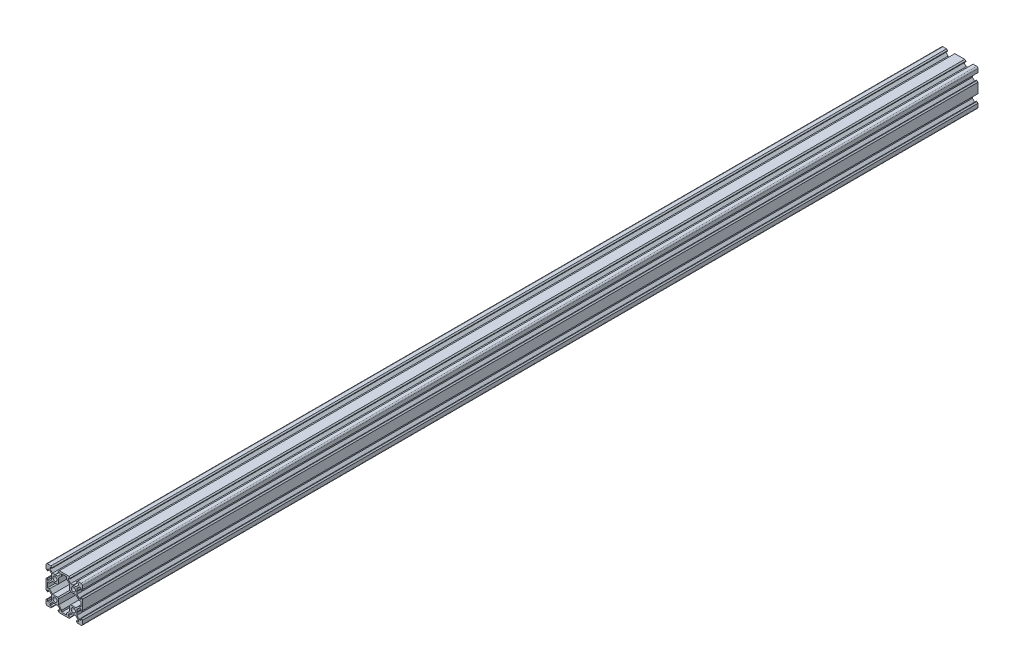
from build123d import *

# Parameters (mm, degrees)
SKETCH1_R           = 2.3
BOSS_EXTRUDE1_DEPTH = 984.25


with BuildPart() as part:
    # Sketch1 → Boss-Extrude1 (new body)
    with BuildSketch(Plane.XY):
        with BuildLine():
            Line((14.58, -20), (18.5, -20))
            ThreePointArc((18.5, -20), (19.560660172, -19.560660172), (20, -18.5))
            Line((20, -18.5), (20, -14.58))
            Line((20, -14.58), (18.815, -13.395))
            Line((18.815, -13.395), (18.2, -13.395))
            Line((18.2, -13.395), (18.2, -15.5))
            Line((18.2, -15.5), (16.560660172, -15.5))
            Line((16.560660172, -15.5), (13.9, -12.839339828))
            Line((13.9, -12.839339828), (13.9, -10.21))
            Line((13.9, -10.21), (13.69, -10))
            Line((13.69, -10), (13.9, -9.79))
            Line((13.9, -9.79), (13.9, -7.160660172))
            Line((13.9, -7.160660172), (16.560660172, -4.5))
            Line((16.560660172, -4.5), (18.2, -4.5))
            Line((18.2, -4.5), (18.2, -6.605))
            Line((18.2, -6.605), (18.815, -6.605))
            Line((18.815, -6.605), (20, -5.42))
            Line((20, -5.42), (20, 5.42))
            Line((20, 5.42), (18.815, 6.605))
            Line((18.815, 6.605), (18.2, 6.605))
            Line((18.2, 6.605), (18.2, 4.5))
            Line((18.2, 4.5), (16.560660172, 4.5))
            Line((16.560660172, 4.5), (13.9, 7.160660172))
            Line((13.9, 7.160660172), (13.9, 9.79))
            Line((13.9, 9.79), (13.69, 10))
            Line((13.69, 10), (13.9, 10.21))
            Line((13.9, 10.21), (13.9, 12.839339828))
            Line((13.9, 12.839339828), (16.560660172, 15.5))
            Line((16.560660172, 15.5), (18.2, 15.5))
            Line((18.2, 15.5), (18.2, 13.395))
            Line((18.2, 13.395), (18.815, 13.395))
            Line((18.815, 13.395), (20, 14.58))
            Line((20, 14.58), (20, 18.5))
            ThreePointArc((20, 18.5), (19.560660172, 19.560660172), (18.5, 20))
            Line((18.5, 20), (14.58, 20))
            Line((14.58, 20), (13.395, 18.815))
            Line((13.395, 18.815), (13.395, 18.2))
            Line((13.395, 18.2), (15.5, 18.2))
            Line((15.5, 18.2), (15.5, 16.560660172))
            Line((15.5, 16.560660172), (12.839339828, 13.9))
            Line((12.839339828, 13.9), (10.21, 13.9))
            Line((10.21, 13.9), (10, 13.69))
            Line((10, 13.69), (9.79, 13.9))
            Line((9.79, 13.9), (7.160660172, 13.9))
            Line((7.160660172, 13.9), (4.5, 16.560660172))
            Line((4.5, 16.560660172), (4.5, 18.2))
            Line((4.5, 18.2), (6.605, 18.2))
            Line((6.605, 18.2), (6.605, 18.815))
            Line((6.605, 18.815), (5.42, 20))
            Line((5.42, 20), (-5.42, 20))
            Line((-5.42, 20), (-6.605, 18.815))
            Line((-6.605, 18.815), (-6.605, 18.2))
            Line((-6.605, 18.2), (-4.5, 18.2))
            Line((-4.5, 18.2), (-4.5, 16.560660172))
            Line((-4.5, 16.560660172), (-7.160660172, 13.9))
            Line((-7.160660172, 13.9), (-9.79, 13.9))
            Line((-9.79, 13.9), (-10, 13.69))
            Line((-10, 13.69), (-10.21, 13.9))
            Line((-10.21, 13.9), (-12.839339828, 13.9))
            Line((-12.839339828, 13.9), (-15.5, 16.560660172))
            Line((-15.5, 16.560660172), (-15.5, 18.2))
            Line((-15.5, 18.2), (-13.395, 18.2))
            Line((-13.395, 18.2), (-13.395, 18.815))
            Line((-13.395, 18.815), (-14.58, 20))
            Line((-14.58, 20), (-18.5, 20))
            ThreePointArc((-18.5, 20), (-19.560660172, 19.560660172), (-20, 18.5))
            Line((-20, 18.5), (-20, 14.58))
            Line((-20, 14.58), (-18.815, 13.395))
            Line((-18.815, 13.395), (-18.2, 13.395))
            Line((-18.2, 13.395), (-18.2, 15.5))
            Line((-18.2, 15.5), (-16.560660172, 15.5))
            Line((-16.560660172, 15.5), (-13.9, 12.839339828))
            Line((-13.9, 12.839339828), (-13.9, 10.21))
            Line((-13.9, 10.21), (-13.69, 10))
            Line((-13.69, 10), (-13.9, 9.79))
            Line((-13.9, 9.79), (-13.9, 7.160660172))
            Line((-13.9, 7.160660172), (-16.560660172, 4.5))
            Line((-16.560660172, 4.5), (-18.2, 4.5))
            Line((-18.2, 4.5), (-18.2, 6.605))
            Line((-18.2, 6.605), (-18.815, 6.605))
            Line((-18.815, 6.605), (-20, 5.42))
            Line((-20, 5.42), (-20, -5.42))
            Line((-20, -5.42), (-18.815, -6.605))
            Line((-18.815, -6.605), (-18.2, -6.605))
            Line((-18.2, -6.605), (-18.2, -4.5))
            Line((-18.2, -4.5), (-16.560660172, -4.5))
            Line((-16.560660172, -4.5), (-13.9, -7.160660172))
            Line((-13.9, -7.160660172), (-13.9, -9.79))
            Line((-13.9, -9.79), (-13.69, -10))
            Line((-13.69, -10), (-13.9, -10.21))
            Line((-13.9, -10.21), (-13.9, -12.839339828))
            Line((-13.9, -12.839339828), (-16.560660172, -15.5))
            Line((-16.560660172, -15.5), (-18.2, -15.5))
            Line((-18.2, -15.5), (-18.2, -13.395))
            Line((-18.2, -13.395), (-18.815, -13.395))
            Line((-18.815, -13.395), (-20, -14.58))
            Line((-20, -14.58), (-20, -18.5))
            ThreePointArc((-20, -18.5), (-19.560660172, -19.560660172), (-18.5, -20))
            Line((-18.5, -20), (-14.58, -20))
            Line((-14.58, -20), (-13.395, -18.815))
            Line((-13.395, -18.815), (-13.395, -18.2))
            Line((-13.395, -18.2), (-15.5, -18.2))
            Line((-15.5, -18.2), (-15.5, -16.560660172))
            Line((-15.5, -16.560660172), (-12.839339828, -13.9))
            Line((-12.839339828, -13.9), (-10.21, -13.9))
            Line((-10.21, -13.9), (-10, -13.69))
            Line((-10, -13.69), (-9.79, -13.9))
            Line((-9.79, -13.9), (-7.160660172, -13.9))
            Line((-7.160660172, -13.9), (-4.5, -16.560660172))
            Line((-4.5, -16.560660172), (-4.5, -18.2))
            Line((-4.5, -18.2), (-6.605, -18.2))
            Line((-6.605, -18.2), (-6.605, -18.815))
            Line((-6.605, -18.815), (-5.42, -20))
            Line((-5.42, -20), (5.42, -20))
            Line((5.42, -20), (6.605, -18.815))
            Line((6.605, -18.815), (6.605, -18.2))
            Line((6.605, -18.2), (4.5, -18.2))
            Line((4.5, -18.2), (4.5, -16.560660172))
            Line((4.5, -16.560660172), (7.160660172, -13.9))
            Line((7.160660172, -13.9), (9.79, -13.9))
            Line((9.79, -13.9), (10, -13.69))
            Line((10, -13.69), (10.21, -13.9))
            Line((10.21, -13.9), (12.839339828, -13.9))
            Line((12.839339828, -13.9), (15.5, -16.560660172))
            Line((15.5, -16.560660172), (15.5, -18.2))
            Line((15.5, -18.2), (13.395, -18.2))
            Line((13.395, -18.2), (13.395, -18.815))
            Line((13.395, -18.815), (14.58, -20))
        make_face()
        with Locations((-10, -10)):
            Circle(SKETCH1_R, mode=Mode.SUBTRACT)
        with Locations((10, -10)):
            Circle(SKETCH1_R, mode=Mode.SUBTRACT)
        Polygon((-16.239339828, -2.7), (-18.2, -2.7), (-18.2, 2.7), (-16.239339828, 2.7), (-12.839339828, 6.1), (-7.160660172, 6.1), (-6.1, 7.160660172), (-6.1, 12.839339828), (-2.7, 16.239339828), (-2.7, 18.2), (2.7, 18.2), (2.7, 16.239339828), (6.1, 12.839339828), (6.1, 7.160660172), (7.160660172, 6.1), (12.839339828, 6.1), (16.239339828, 2.7), (18.2, 2.7), (18.2, -2.7), (16.239339828, -2.7), (12.839339828, -6.1), (7.160660172, -6.1), (6.1, -7.160660172), (6.1, -12.839339828), (2.7, -16.239339828), (2.7, -18.2), (-2.7, -18.2), (-2.7, -16.239339828), (-6.1, -12.839339828), (-6.1, -7.160660172), (-7.160660172, -6.1), (-12.839339828, -6.1), align=None, mode=Mode.SUBTRACT)
        with Locations((-10, 10)):
            Circle(SKETCH1_R, mode=Mode.SUBTRACT)
        with Locations((10, 10)):
            Circle(SKETCH1_R, mode=Mode.SUBTRACT)
    extrude(amount=BOSS_EXTRUDE1_DEPTH)


solid = part.part
